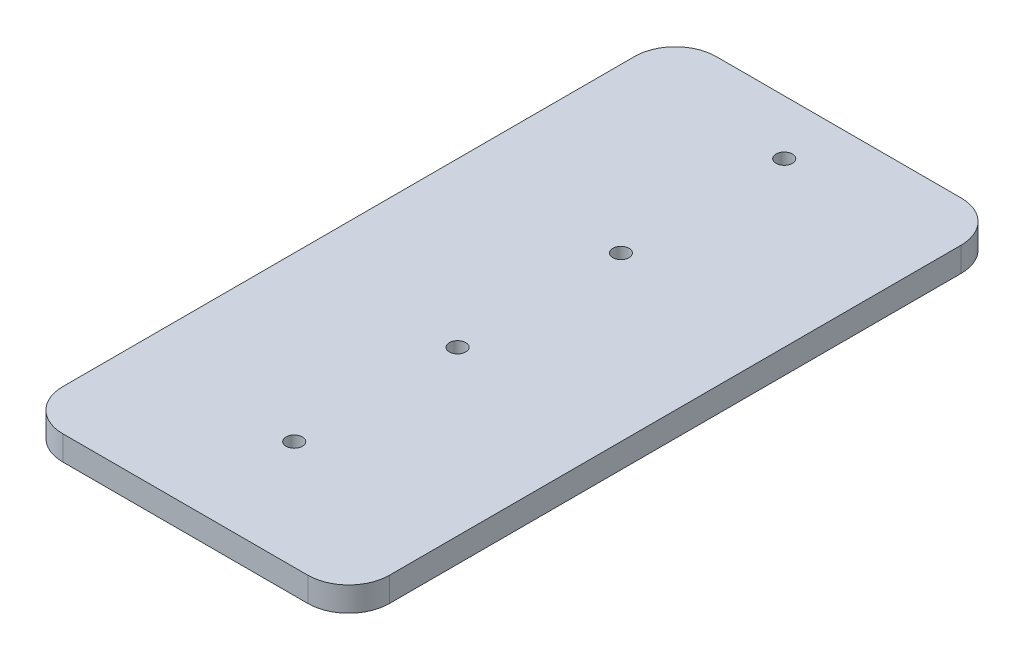
from build123d import *

# Parameters (mm, degrees)
SKETCH1_R           = 2
BOSS_EXTRUDE1_DEPTH = 6
SCALE1_SCALE        = 7.5


with BuildPart() as part:
    # Sketch1 → Boss-Extrude1 (new body)
    with BuildSketch(Plane(origin=(0, 0, 0), x_dir=(1, 0, 0), z_dir=(0, 1, 0))):
        with BuildLine():
            Line((-27, -27), (-27, -47))
            ThreePointArc((-27, -47), (-24.071067812, -54.071067812), (-17, -57))
            Line((-17, -57), (43, -57))
            ThreePointArc((43, -57), (50.071067812, -54.071067812), (53, -47))
            Line((53, -47), (53, -27))
            Line((53, -27), (53, 93))
            ThreePointArc((53, 93), (50.071067812, 100.071067812), (43, 103))
            Line((43, 103), (-17, 103))
            ThreePointArc((-17, 103), (-24.071067812, 100.071067812), (-27, 93))
            Line((-27, 93), (-27, -27))
        make_face()
        with Locations((13, 89.666666667)):
            Circle(SKETCH1_R, mode=Mode.SUBTRACT)
        with Locations((13, 49.666666667)):
            Circle(SKETCH1_R, mode=Mode.SUBTRACT)
        with Locations((13, 9.666666667)):
            Circle(SKETCH1_R, mode=Mode.SUBTRACT)
        with Locations((13, -30.333333333)):
            Circle(SKETCH1_R, mode=Mode.SUBTRACT)
    extrude(amount=BOSS_EXTRUDE1_DEPTH)


with BuildPart() as part_1:
    # Scale1: scaled about (13, 3, -22.97353869)
    add(part.part.scale(SCALE1_SCALE).moved(Location((-84.5, -19.5, 149.328001485))))


solid = part_1.part
